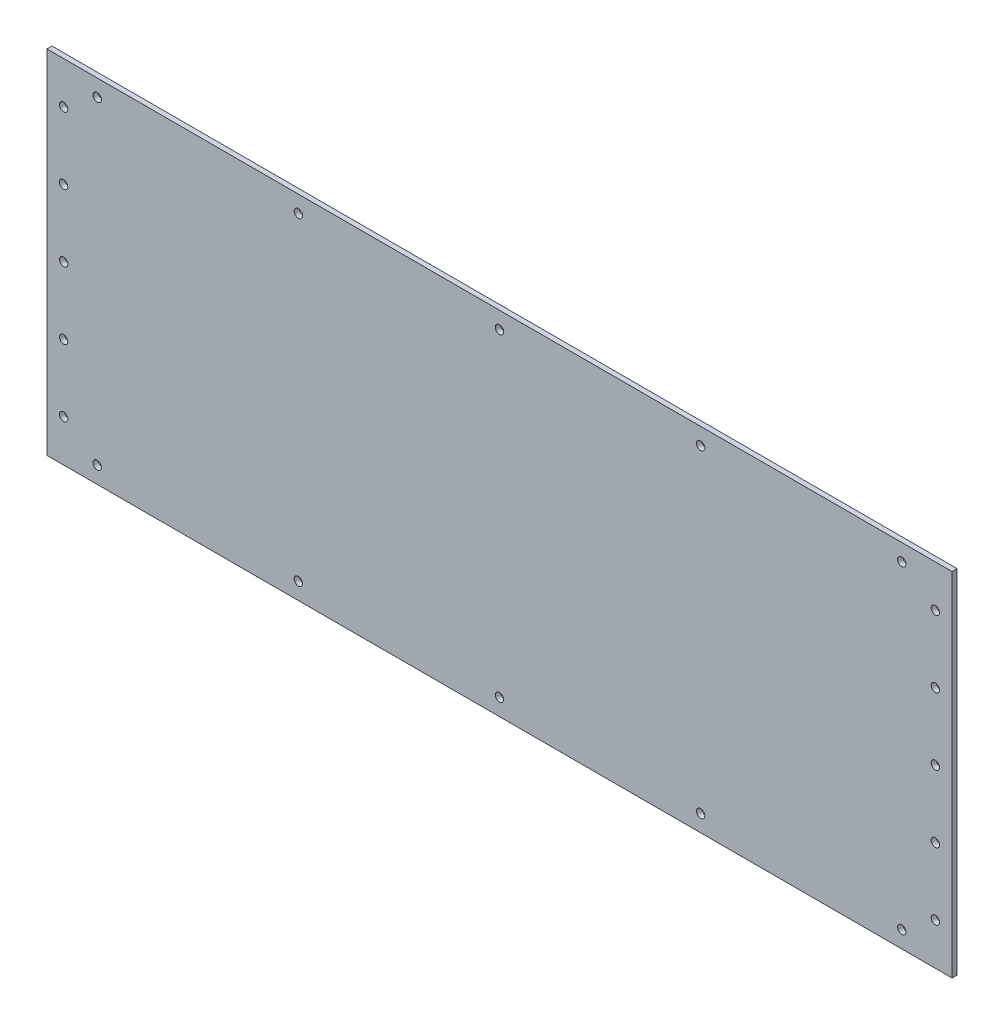
from build123d import *

# Parameters (mm, degrees)
CROQUIS1_W              = 540
CROQUIS1_H              = 210
SALIENTE_EXTRUIR1_DEPTH = 3
CROQUIS2_R              = 2.5
CORTAR_EXTRUIR2_DEPTH   = 4


with BuildPart() as part:
    # Croquis1 → Saliente-Extruir1 (new body)
    with BuildSketch(Plane.XY):
        Rectangle(CROQUIS1_W, CROQUIS1_H)
    extrude(amount=SALIENTE_EXTRUIR1_DEPTH)

    # Croquis2 → Cortar-Extruir2 (cut, through all)
    with BuildSketch(Plane.XY.offset(3)):
        with Locations((0, 95)):
            Circle(CROQUIS2_R)
        with Locations((-260, 0)):
            Circle(CROQUIS2_R)
        with Locations((0, -95)):
            Circle(CROQUIS2_R)
        with Locations((260, 0)):
            Circle(CROQUIS2_R)
        with Locations((120, 95)):
            Circle(CROQUIS2_R)
        with Locations((240, 95)):
            Circle(CROQUIS2_R)
        with Locations((-120, 95)):
            Circle(CROQUIS2_R)
        with Locations((-240, 95)):
            Circle(CROQUIS2_R)
        with Locations((-260, -40)):
            Circle(CROQUIS2_R)
        with Locations((-260, -80)):
            Circle(CROQUIS2_R)
        with Locations((-260, 40)):
            Circle(CROQUIS2_R)
        with Locations((-260, 80)):
            Circle(CROQUIS2_R)
        with Locations((120, -95)):
            Circle(CROQUIS2_R)
        with Locations((240, -95)):
            Circle(CROQUIS2_R)
        with Locations((-120, -95)):
            Circle(CROQUIS2_R)
        with Locations((-240, -95)):
            Circle(CROQUIS2_R)
        with Locations((260, 40)):
            Circle(CROQUIS2_R)
        with Locations((260, 80)):
            Circle(CROQUIS2_R)
        with Locations((260, -40)):
            Circle(CROQUIS2_R)
        with Locations((260, -80)):
            Circle(CROQUIS2_R)
    extrude(amount=-CORTAR_EXTRUIR2_DEPTH, mode=Mode.SUBTRACT)


solid = part.part
